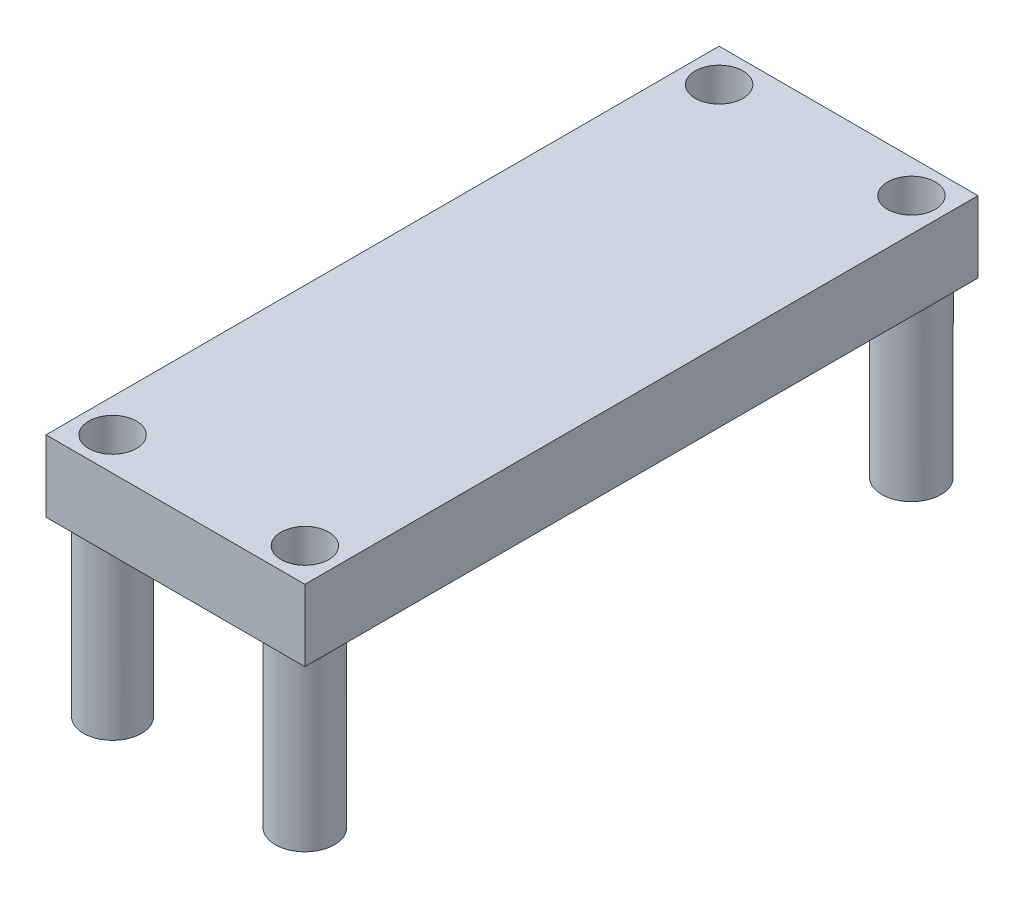
from build123d import *

# Parameters (mm, degrees)
SKETCH1_W           = 17.78
SKETCH1_H           = 46.228
BOSS_EXTRUDE1_DEPTH = 4.9022
SKETCH2_R           = 1.9939
SKETCH2_R_2         = 2.032
BOSS_EXTRUDE2_DEPTH = 11.8618
SKETCH3_R           = 1.6383
CUT_EXTRUDE1_DEPTH  = 17.764


with BuildPart() as part:
    # Sketch1 → Boss-Extrude1 (new body)
    with BuildSketch(Plane(origin=(0, 0, 0), x_dir=(1, 0, 0), z_dir=(0, 1, 0))):
        with Locations((-7.973944862, -11.637942607)):
            Rectangle(SKETCH1_W, SKETCH1_H)
    extrude(amount=BOSS_EXTRUDE1_DEPTH)

    # Sketch2 → Boss-Extrude2 (add)
    with BuildSketch(Plane.XZ):
        with Locations((-14.577944862, 32.465942607)):
            Circle(SKETCH2_R)
        with Locations((-1.369944862, 32.465942607)):
            Circle(SKETCH2_R_2)
        with Locations((-1.369944862, -9.190057393)):
            Circle(SKETCH2_R_2)
        with Locations((-14.577944862, -9.190057393)):
            Circle(SKETCH2_R_2)
    extrude(amount=BOSS_EXTRUDE2_DEPTH)

    # Sketch3 → Cut-Extrude1 (cut, through all)
    with BuildSketch(Plane.XZ.offset(11.8618)):
        with Locations((-14.577944862, 32.465942607)):
            Circle(SKETCH3_R)
        with Locations((-14.577944862, -9.190057393)):
            Circle(SKETCH3_R)
        with Locations((-1.369944862, -9.190057393)):
            Circle(SKETCH3_R)
        with Locations((-1.369944862, 32.465942607)):
            Circle(SKETCH3_R)
    extrude(amount=-CUT_EXTRUDE1_DEPTH, mode=Mode.SUBTRACT)


solid = part.part
